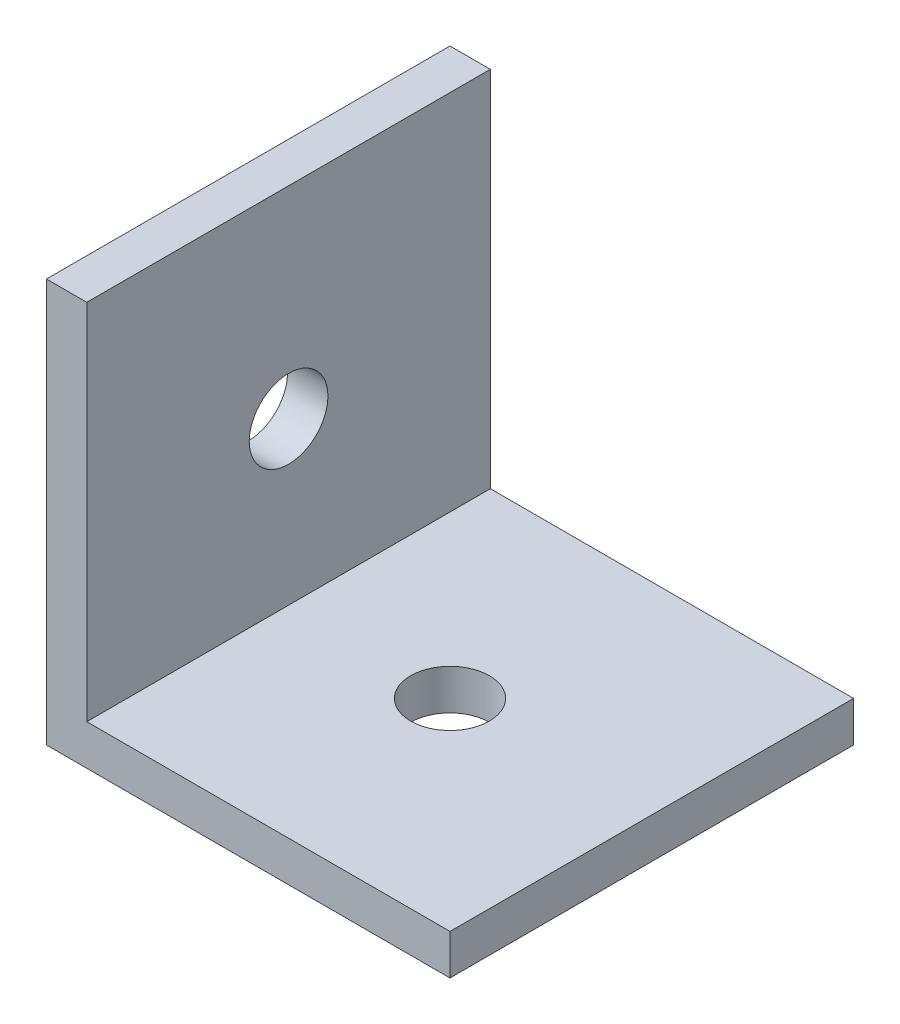
from build123d import *

# Parameters (mm, degrees)
EXTRUDE_THIN1_DEPTH = 25.4
SKETCH3_R           = 2.4765
CUT_EXTRUDE1_DEPTH  = 26.4
SKETCH4_R           = 2.4765
CUT_EXTRUDE2_DEPTH  = 26.4


with BuildPart() as part:
    # Sketch1 → Extrude-Thin1 (new body)
    with BuildSketch(Plane.XY):
        Polygon((25.4, 0), (0, 0), (0, 25.4), (2.54, 25.4), (2.54, 2.54), (25.4, 2.54), align=None)
    extrude(amount=EXTRUDE_THIN1_DEPTH)

    # Sketch3 → Cut-Extrude1 (cut, through all)
    with BuildSketch(Plane.ZY):
        with Locations((12.7, 12.7)):
            Circle(SKETCH3_R)
    extrude(amount=-CUT_EXTRUDE1_DEPTH, mode=Mode.SUBTRACT)

    # Sketch4 → Cut-Extrude2 (cut, through all)
    with BuildSketch(Plane.XZ):
        with Locations((12.7, 12.7)):
            Circle(SKETCH4_R)
    extrude(amount=-CUT_EXTRUDE2_DEPTH, mode=Mode.SUBTRACT)


solid = part.part
